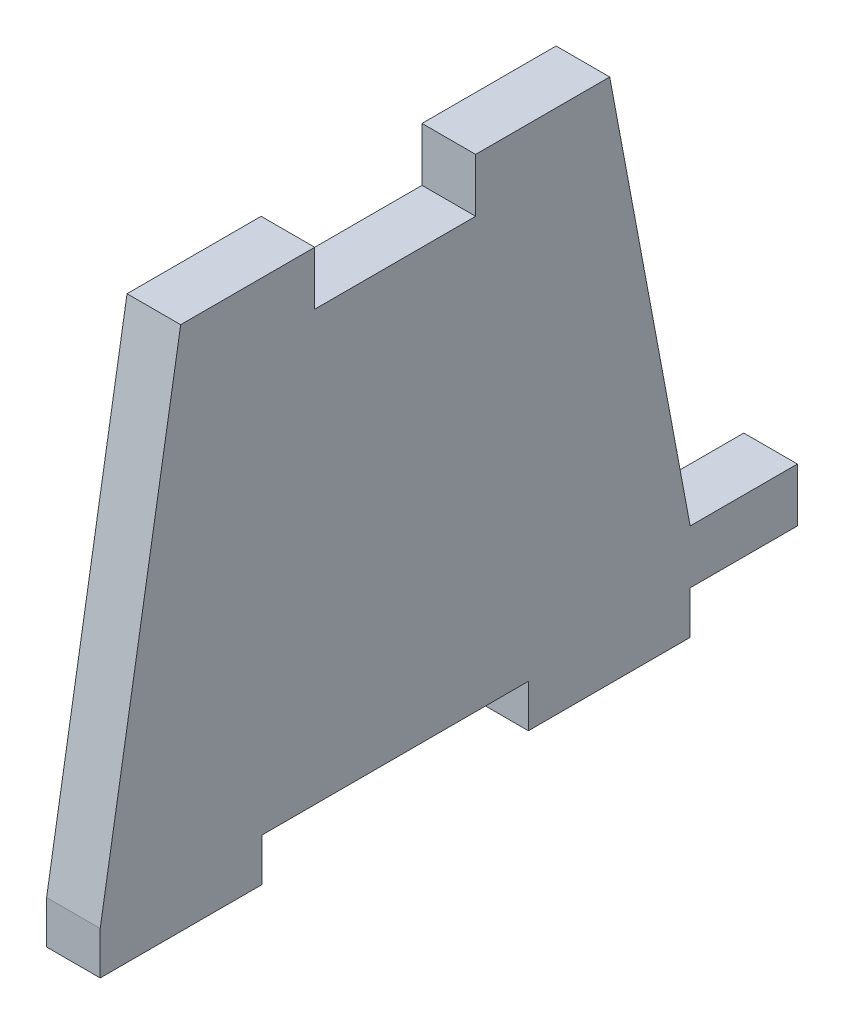
from build123d import *

# Parameters (mm, degrees)
BOSS_EXTRUDE1_DEPTH = 1.5875


with BuildPart() as part:
    # Sketch1 → Boss-Extrude1 (new body, symmetric)
    with BuildSketch(Plane(origin=(0, 0, 0), x_dir=(0, 0, -1), z_dir=(1, 0, 0))):
        Polygon((23.8125, 0), (23.8125, 3.175), (17.4625, 3.175), (12.7, 28.575), (4.7625, 28.575), (4.7625, 25.4), (-4.7625, 25.4), (-4.7625, 28.575), (-12.7, 28.575), (-17.4625, 0), (-17.4625, -2.54), (-7.8867, -2.54), (-7.8867, 0), (7.8867, 0), (7.8867, -2.54), (17.4625, -2.54), (17.4625, 0), align=None)
    extrude(amount=BOSS_EXTRUDE1_DEPTH, both=True)


solid = part.part
